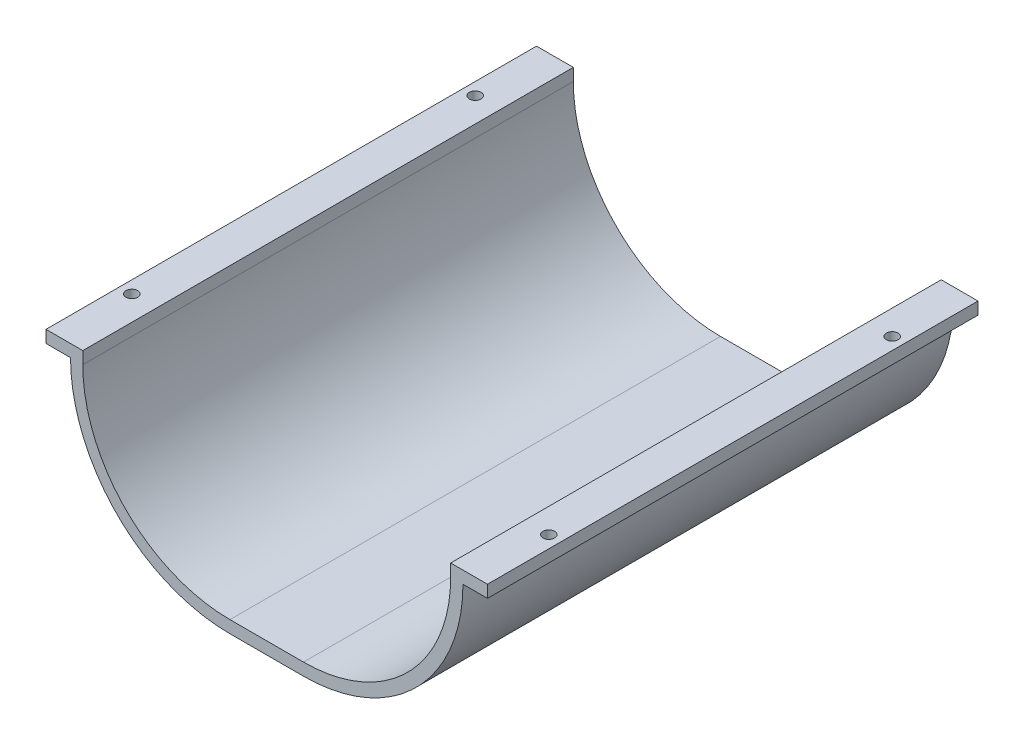
from build123d import *

# Parameters (mm, degrees)
SKETCH1_W           = 10
SKETCH1_H           = 5
BOSS_EXTRUDE1_DEPTH = 200
SKETCH2_R           = 2.38125
CUT_EXTRUDE1_DEPTH  = 200


with BuildPart() as part:
    # Sketch1 → Boss-Extrude1 (new body)
    with BuildSketch(Plane.XY):
        with Locations((-10, 62.5)):
            Rectangle(SKETCH1_W, SKETCH1_H)
        with BuildLine():
            Line((90, 0), (60, 0))
            ThreePointArc((60, 0), (17.573593129, 17.573593129), (0, 60))
            Line((0, 60), (0, 65))
            Line((0, 65), (-5, 65))
            Line((-5, 65), (-5, 60))
            ThreePointArc((-5, 60), (14.038059223, 14.038059223), (60, -5))
            Line((60, -5), (90, -5))
            ThreePointArc((90, -5), (135.961940777, 14.038059223), (155, 60))
            Line((155, 60), (155, 65))
            Line((155, 65), (150, 65))
            Line((150, 65), (150, 60))
            ThreePointArc((150, 60), (132.426406871, 17.573593129), (90, 0))
        make_face()
        with Locations((160, 62.5)):
            Rectangle(SKETCH1_W, SKETCH1_H)
    extrude(amount=BOSS_EXTRUDE1_DEPTH)

    # Sketch2 → Cut-Extrude1 (cut)
    with BuildSketch(Plane(origin=(0, 65, 0), x_dir=(1, 0, 0), z_dir=(0, 1, 0))):
        with Locations((-10, -170)):
            Circle(SKETCH2_R)
        with Locations((-10, -30)):
            Circle(SKETCH2_R)
        with Locations((160, -30)):
            Circle(SKETCH2_R)
        with Locations((160, -170)):
            Circle(SKETCH2_R)
    extrude(amount=-CUT_EXTRUDE1_DEPTH, mode=Mode.SUBTRACT)


solid = part.part
